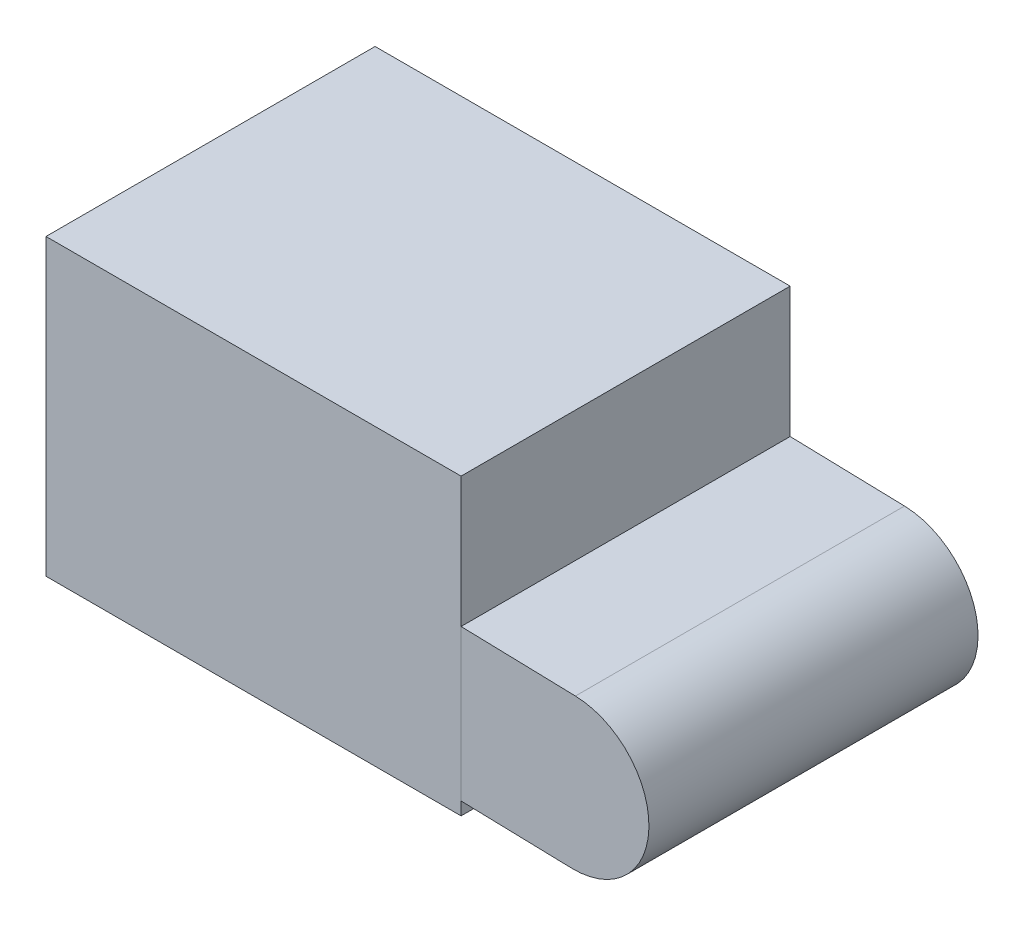
from build123d import *

# Parameters (mm, degrees)
SKETCH2_W           = 64.325846528
SKETCH2_H           = 45.60668484
BOSS_EXTRUDE1_DEPTH = 51
BOSS_EXTRUDE2_DEPTH = 51


with BuildPart() as part:
    # Sketch2 → Boss-Extrude1 (new body)
    with BuildSketch(Plane.XY):
        with Locations((-14.464806759, -12.422716393)):
            Rectangle(SKETCH2_W, SKETCH2_H)
    extrude(amount=BOSS_EXTRUDE1_DEPTH)


with BuildPart() as body_2:
    # Sketch3 → Boss-Extrude2 (new body)
    with BuildSketch(Plane.XY):
        with BuildLine():
            Line((34.79695587, -33.674535843), (4.036573747, -32.85752552))
            ThreePointArc((4.036573747, -32.85752552), (-7.352539417, -20.846904325), (4.658081778, -9.457791161))
            Line((4.658081778, -9.457791161), (35.418463901, -10.274801484))
            ThreePointArc((35.418463901, -10.274801484), (46.807577065, -22.285422679), (34.79695587, -33.674535843))
        make_face()
    extrude(amount=BOSS_EXTRUDE2_DEPTH)


solid = Compound([part.part, body_2.part])
